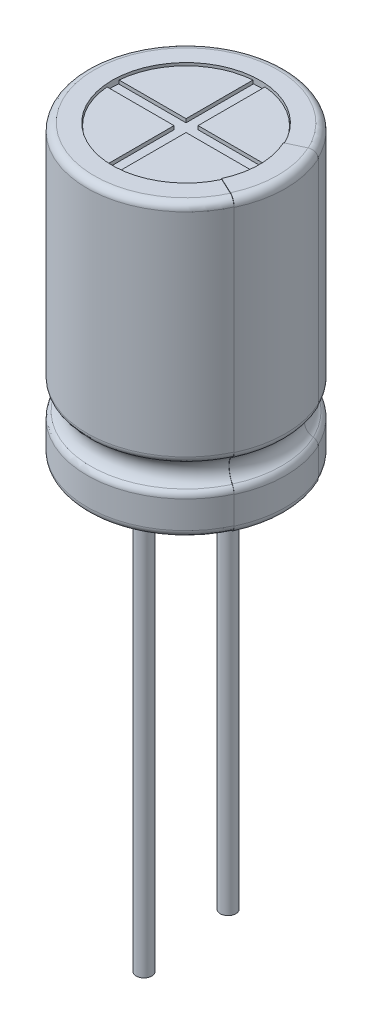
from build123d import *

# Parameters (mm, degrees)
BOSS_EXTRUDE1_DEPTH      = 0.15
BOSS_EXTRUDE1_2_DEPTH    = 0.15
BOSS_EXTRUDE1_3_DEPTH    = 0.15
BOSS_EXTRUDE1_4_DEPTH    = 0.15
SKETCH3_R                = 2.5
SKETCH3_RX               = 2.2
SKETCH3_RY               = 1.7
BOSS_EXTRUDE2_DEPTH      = 0.6
REVOLVE3_ANGLE           = 25
REVOLVE3_OTHER_WAY_ANGLE = 25
SKETCH7_R                = 0.325
BOSS_EXTRUDE3_DEPTH      = 19.6
SKETCH7_4_R              = 0.325
BOSS_EXTRUDE4_DEPTH      = 15.6


with BuildPart() as part:
    # Sketch1 → Revolve1 (revolve)
    with BuildSketch(Plane.XY, mode=Mode.PRIVATE) as revolve1_sk:
        with BuildLine():
            Line((0, 0.6), (3.125, 0.6))
            Line((3.125, 0.6), (3.125, 0.4))
            Line((3.125, 0.4), (3.825, 0.4))
            ThreePointArc((3.825, 0.4), (4.037132034, 0.487867966), (4.125, 0.7))
            Line((4.125, 0.7), (4.125, 1.841493624))
            ThreePointArc((4.125, 1.841493624), (4.085692429, 1.989950545), (3.978070284, 2.09950426))
            ThreePointArc((3.978070284, 2.09950426), (3.6930522, 2.6), (3.978070284, 3.10049574))
            ThreePointArc((3.978070284, 3.10049574), (4.085692429, 3.210049455), (4.125, 3.358506376))
            Line((4.125, 3.358506376), (4.125, 12.2))
            ThreePointArc((4.125, 12.2), (4.037132034, 12.412132034), (3.825, 12.5))
            Line((3.825, 12.5), (3.075, 12.5))
            Line((3.075, 12.5), (3.075, 12.25))
            Line((3.075, 12.25), (0, 12.25))
            Line((0, 12.25), (0, 0.6))
        make_face()
    revolve(revolve1_sk.sketch.rotate(Axis((0, 12.25, 0), (0, -1, 0)), 180), axis=Axis((0, 12.25, 0), (0, -1, 0)))



with BuildPart() as body_2:
    # Sketch2 → Boss-Extrude1 (new body)
    with BuildSketch(Plane(origin=(0, 12.25, 0), x_dir=(1, 0, 0), z_dir=(0, 1, 0))):
        with BuildLine():
            Line((-0.25, 0.25), (-0.25, 3.039736831))
            ThreePointArc((-0.25, 3.039736831), (-2.156675683, 2.156675683), (-3.039736831, 0.25))
            Line((-3.039736831, 0.25), (-0.25, 0.25))
        make_face()
    extrude(amount=BOSS_EXTRUDE1_DEPTH)


with BuildPart() as body_3:
    # Sketch2 → Boss-Extrude1 2 (new body)
    with BuildSketch(Plane(origin=(0, 12.25, 0), x_dir=(1, 0, 0), z_dir=(0, 1, 0))):
        with BuildLine():
            Line((0.25, -3.039736831), (0.25, -0.25))
            Line((0.25, -0.25), (3.039736831, -0.25))
            ThreePointArc((3.039736831, -0.25), (2.156675683, -2.156675683), (0.25, -3.039736831))
        make_face()
    extrude(amount=BOSS_EXTRUDE1_2_DEPTH)


with BuildPart() as body_4:
    # Sketch2 → Boss-Extrude1 3 (new body)
    with BuildSketch(Plane(origin=(0, 12.25, 0), x_dir=(1, 0, 0), z_dir=(0, 1, 0))):
        with BuildLine():
            Line((-0.25, -3.039736831), (-0.25, -0.25))
            Line((-0.25, -0.25), (-3.039736831, -0.25))
            ThreePointArc((-3.039736831, -0.25), (-2.156675683, -2.156675683), (-0.25, -3.039736831))
        make_face()
    extrude(amount=BOSS_EXTRUDE1_3_DEPTH)


with BuildPart() as body_5:
    # Sketch2 → Boss-Extrude1 4 (new body)
    with BuildSketch(Plane(origin=(0, 12.25, 0), x_dir=(1, 0, 0), z_dir=(0, 1, 0))):
        with BuildLine():
            Line((0.25, 0.25), (0.25, 3.039736831))
            ThreePointArc((0.25, 3.039736831), (2.156675683, 2.156675683), (3.039736831, 0.25))
            Line((3.039736831, 0.25), (0.25, 0.25))
        make_face()
    extrude(amount=BOSS_EXTRUDE1_4_DEPTH)


with BuildPart() as body_6:
    # Sketch3 → Boss-Extrude2 (new body)
    with BuildSketch(Plane.XZ.offset(-0.6)):
        Circle(SKETCH3_R)
        with Locations(Location((0, 0), (0, 0, 180))):
            Ellipse(SKETCH3_RX, SKETCH3_RY, mode=Mode.SUBTRACT)
    extrude(amount=BOSS_EXTRUDE2_DEPTH)


with BuildPart() as body_7:
    # Sketch5 → Revolve3 (revolve)
    with BuildSketch(Plane.XY):
        with BuildLine():
            Line((4.145, 12.2), (4.145, 3.358506376))
            ThreePointArc((4.145, 3.358506376), (4.103071924, 3.200152326), (3.988274969, 3.083295031))
            ThreePointArc((3.988274969, 3.083295031), (3.7130522, 2.6), (3.988274969, 2.116704969))
            ThreePointArc((3.988274969, 2.116704969), (4.103071924, 1.999847674), (4.145, 1.841493624))
            Line((4.145, 1.841493624), (4.145, 0.7))
            ThreePointArc((4.145, 0.7), (4.05127417, 0.47372583), (3.825, 0.38))
            Line((3.825, 0.38), (3.105082474, 0.38))
            Line((3.105082474, 0.38), (3.054917185, 12.52))
            Line((3.054917185, 12.52), (3.825, 12.52))
            ThreePointArc((3.825, 12.52), (4.05127417, 12.42627417), (4.145, 12.2))
        make_face()
        with BuildLine():
            Line((3.075, 12.5), (3.825, 12.5))
            ThreePointArc((3.825, 12.5), (4.037132034, 12.412132034), (4.125, 12.2))
            Line((4.125, 12.2), (4.125, 3.358506376))
            ThreePointArc((4.125, 3.358506376), (4.085692429, 3.210049455), (3.978070284, 3.10049574))
            ThreePointArc((3.978070284, 3.10049574), (3.6930522, 2.6), (3.978070284, 2.09950426))
            ThreePointArc((3.978070284, 2.09950426), (4.085692429, 1.989950545), (4.125, 1.841493624))
            Line((4.125, 1.841493624), (4.125, 0.7))
            ThreePointArc((4.125, 0.7), (4.037132034, 0.487867966), (3.825, 0.4))
            Line((3.825, 0.4), (3.125, 0.4))
            Line((3.125, 0.4), (3.075, 12.5))
        make_face(mode=Mode.SUBTRACT)
    revolve(axis=Axis((0, 0, 0), (0, 1, 0)), revolution_arc=REVOLVE3_ANGLE)

    # Sketch5 → Revolve3 other way (revolve)
    with BuildSketch(Plane.XY):
        with BuildLine():
            Line((4.145, 12.2), (4.145, 3.358506376))
            ThreePointArc((4.145, 3.358506376), (4.103071924, 3.200152326), (3.988274969, 3.083295031))
            ThreePointArc((3.988274969, 3.083295031), (3.7130522, 2.6), (3.988274969, 2.116704969))
            ThreePointArc((3.988274969, 2.116704969), (4.103071924, 1.999847674), (4.145, 1.841493624))
            Line((4.145, 1.841493624), (4.145, 0.7))
            ThreePointArc((4.145, 0.7), (4.05127417, 0.47372583), (3.825, 0.38))
            Line((3.825, 0.38), (3.105082474, 0.38))
            Line((3.105082474, 0.38), (3.054917185, 12.52))
            Line((3.054917185, 12.52), (3.825, 12.52))
            ThreePointArc((3.825, 12.52), (4.05127417, 12.42627417), (4.145, 12.2))
        make_face()
        with BuildLine():
            Line((3.075, 12.5), (3.825, 12.5))
            ThreePointArc((3.825, 12.5), (4.037132034, 12.412132034), (4.125, 12.2))
            Line((4.125, 12.2), (4.125, 3.358506376))
            ThreePointArc((4.125, 3.358506376), (4.085692429, 3.210049455), (3.978070284, 3.10049574))
            ThreePointArc((3.978070284, 3.10049574), (3.6930522, 2.6), (3.978070284, 2.09950426))
            ThreePointArc((3.978070284, 2.09950426), (4.085692429, 1.989950545), (4.125, 1.841493624))
            Line((4.125, 1.841493624), (4.125, 0.7))
            ThreePointArc((4.125, 0.7), (4.037132034, 0.487867966), (3.825, 0.4))
            Line((3.825, 0.4), (3.125, 0.4))
            Line((3.125, 0.4), (3.075, 12.5))
        make_face(mode=Mode.SUBTRACT)
    revolve(axis=Axis((0, 0, 0), (0, -1, 0)), revolution_arc=REVOLVE3_OTHER_WAY_ANGLE)


with BuildPart() as part_1:
    add(part.part)

    add(body_6.part)  # Boss-Extrude3 merges body 6
    # Sketch7 → Boss-Extrude3 (add)
    with BuildSketch(Plane.XZ.offset(-0.6)):
        with Locations(Location((-1.75, 0, 0), (0, 0, 180))):
            Circle(SKETCH7_R)
    extrude(amount=BOSS_EXTRUDE3_DEPTH)

    # Sketch7_4 → Boss-Extrude4 (add)
    with BuildSketch(Plane.XZ.offset(-0.6)):
        with Locations(Location((1.75, 0, 0), (0, 0, 180))):
            Circle(SKETCH7_4_R)
    extrude(amount=BOSS_EXTRUDE4_DEPTH)


solid = Compound([body_2.part, body_3.part, body_4.part, body_5.part, body_7.part, part_1.part])
